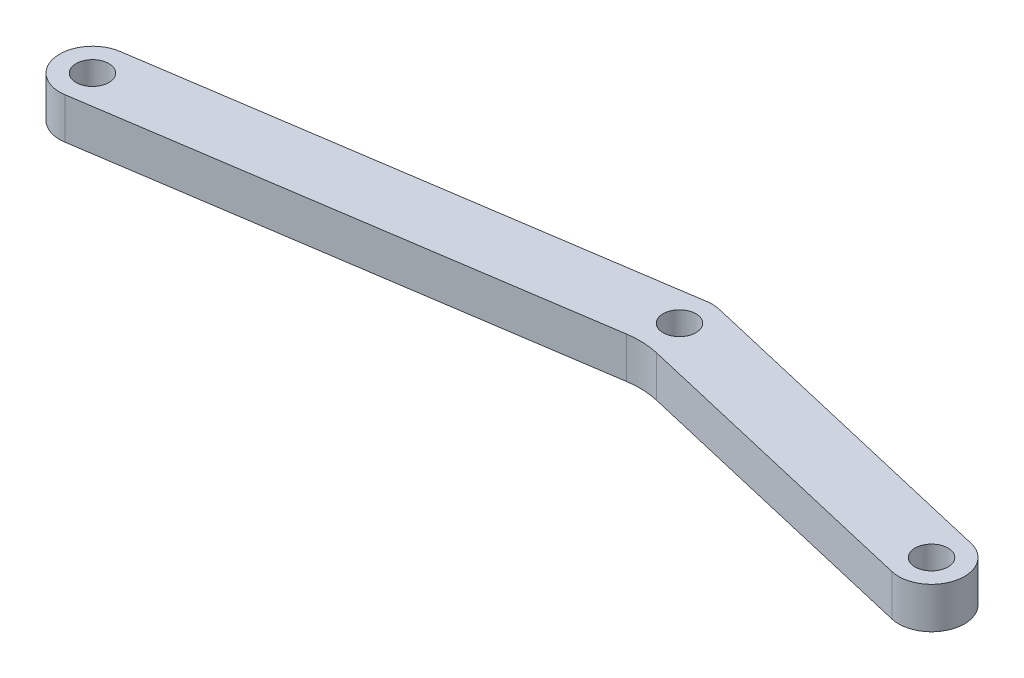
from build123d import *

# Parameters (mm, degrees)
SKETCH_1_R      = 2
EXTRUDE_1_DEPTH = 5
FILLET_2_R      = 10


with BuildPart() as part:
    # 草图1 → 凸台-拉伸1 (new body)
    with BuildSketch(Plane(origin=(0, 0, 0), x_dir=(1, 0, 0), z_dir=(0, 1, 0))):
        with BuildLine():
            Line((10.425672389, 13.301374756), (-51.617327611, 3.955374756))
            ThreePointArc((-51.617327611, 3.955374756), (-54.976874756, -0.595827611), (-50.425672389, -3.955374756))
            Line((-50.425672389, -3.955374756), (10.858587818, 5.276330608))
            Line((10.858587818, 5.276330608), (50.11141182, -3.89509172))
            ThreePointArc((50.11141182, -3.89509172), (54.91659172, -0.91008818), (51.93158818, 3.89509172))
            Line((51.93158818, 3.89509172), (11.93158818, 13.24109172))
            ThreePointArc((11.93158818, 13.24109172), (11.181495117, 13.342798914), (10.425672389, 13.301374756))
        make_face()
        with Locations((-51.0215, 0)):
            Circle(SKETCH_1_R, mode=Mode.SUBTRACT)
        with Locations((11.0215, 9.346)):
            Circle(SKETCH_1_R, mode=Mode.SUBTRACT)
        with Locations((51.0215, 0)):
            Circle(SKETCH_1_R, mode=Mode.SUBTRACT)
    extrude(amount=EXTRUDE_1_DEPTH)

    # 圆角2
    fillet_2_edges = [part.edges().sort_by_distance(p)[0] for p in [
        (10.858587818, 2.5, -5.276330608),
    ]]
    fillet(fillet_2_edges, radius=FILLET_2_R)


solid = part.part
